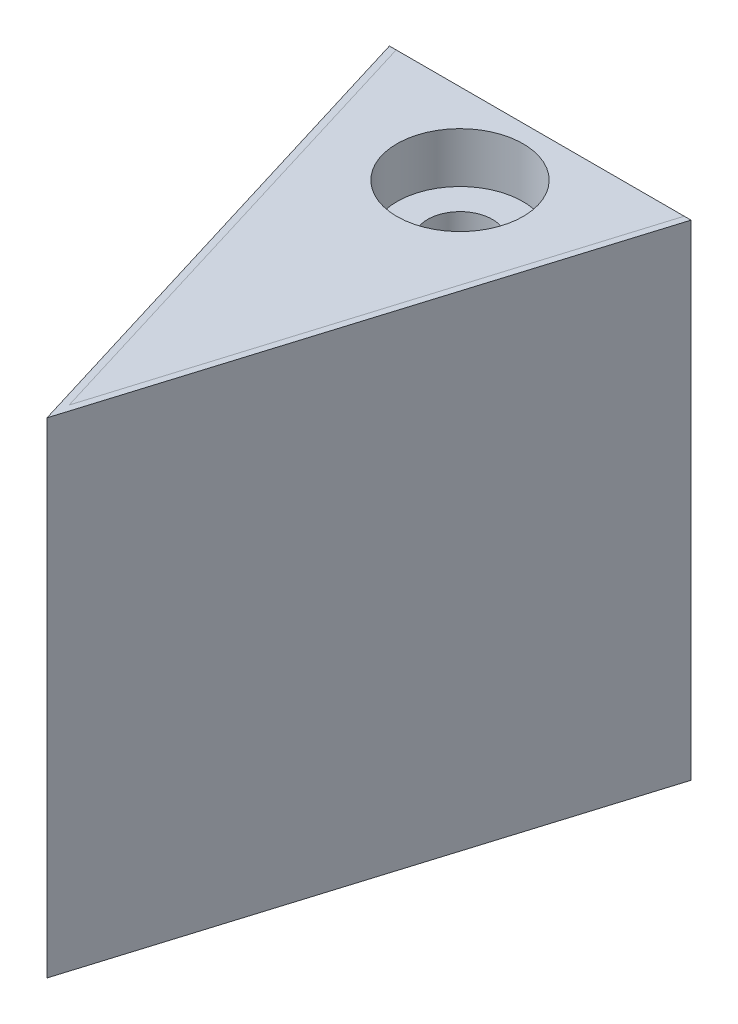
from build123d import *

# Parameters (mm, degrees)
BOSS_EXTRUDE1_DEPTH      = 12.5
BOSS_EXTRUDE1_DEPTH_BACK = 2.5
CUT_EXTRUDE1_DEPTH       = 5
SKETCH5_R                = 1
CUT_EXTRUDE2_DEPTH       = 22.965235397
CUT_EXTRUDE2_DEPTH_BACK  = 22.965235397
SKETCH6_R                = 1.95
CUT_EXTRUDE3_DEPTH       = 1.55
SPLIT2_SURFACE_1_BACK    = 24.335
SPLIT2_SURFACE_1_DEPTH   = 48.67
SPLIT2_SURFACE_2_BACK    = 24.335
SPLIT2_SURFACE_2_DEPTH   = 48.67


with BuildPart() as part:
    # Sketch1 → Boss-Extrude1 (new, two sides)
    with BuildSketch(Plane(origin=(0, 0, 0), x_dir=(1, 0, 0), z_dir=(0, 1, 0))) as boss_extrude1_sk:
        Polygon((4.642363604, -4.565370009), (-4.68242218, -4.565370009), (-1.013654003, -16.565370009), (-0.020029288, -19.815370009), (0.973595427, -16.565370009), align=None)
    extrude(amount=BOSS_EXTRUDE1_DEPTH)
    extrude(boss_extrude1_sk.sketch, amount=-BOSS_EXTRUDE1_DEPTH_BACK)

    # Sketch2 → Cut-Extrude1 (cut)
    with BuildSketch(Plane(origin=(0, 0, 4.565370009), x_dir=(-1, 0, 0), z_dir=(0, 0, -1))):
        with BuildLine():
            Line((-2.878246061, 5.95), (2.918304637, 5.95))
            ThreePointArc((2.918304637, 5.95), (0.020029288, 8.05), (-2.878246061, 5.95))
        make_face()
        with BuildLine():
            Line((-2.878246061, 4.05), (2.918304637, 4.05))
            ThreePointArc((2.918304637, 4.05), (0.020029288, 1.95), (-2.878246061, 4.05))
        make_face()
    extrude(amount=-CUT_EXTRUDE1_DEPTH, mode=Mode.SUBTRACT)

    # Sketch5 → Cut-Extrude2 (cut, two sides)
    with BuildSketch(Plane(origin=(0, 5.74, 0), x_dir=(1, 0, 0), z_dir=(0, 1, 0))) as cut_extrude2_sk:
        with Locations(Location((0, -7.065370009, 0), (0, 0, 270))):
            Circle(SKETCH5_R)
    extrude(amount=CUT_EXTRUDE2_DEPTH, mode=Mode.SUBTRACT)
    extrude(cut_extrude2_sk.sketch, amount=-CUT_EXTRUDE2_DEPTH_BACK, mode=Mode.SUBTRACT)

    # Sketch6 → Cut-Extrude3 (cut)
    with BuildSketch(Plane(origin=(0, 12.5, 0), x_dir=(1, 0, 0), z_dir=(0, 1, 0))):
        with Locations(Location((0, -7.065370009, 0), (0, 0, 270))):
            Circle(SKETCH6_R)
    extrude(amount=-CUT_EXTRUDE3_DEPTH, mode=Mode.SUBTRACT)


with BuildPart() as body_2:
    # Split2: the piece behind the surface
    add(part.part)
    # Split2 surface: a surface, the sketch's curves swept straight by 48.67 mm
    with BuildLine(Plane(origin=(0, 12.5, 0), x_dir=(1, 0, 0), z_dir=(0, 1, 0)).offset(-SPLIT2_SURFACE_1_BACK), mode=Mode.PRIVATE) as split2_surface_1_path:
        Line((-4.68242218, -4.565370009), (-0.020029288, -19.815370009))
        Line((-0.020029288, -19.815370009), (4.642363604, -4.565370009))
        Line((4.642363604, -4.565370009), (4.433225253, -4.565370009))
        Line((4.433225253, -4.565370009), (-0.020029288, -19.131309285))
        Line((-0.020029288, -19.131309285), (-4.473283829, -4.565370009))
        Line((-4.473283829, -4.565370009), (-4.68242218, -4.565370009))
    split2_surface_1 = Shell.extrude(split2_surface_1_path.wire(), (0 * SPLIT2_SURFACE_1_DEPTH, 1 * SPLIT2_SURFACE_1_DEPTH, 0 * SPLIT2_SURFACE_1_DEPTH))
    split(bisect_by=split2_surface_1, keep=Keep.BOTTOM)


with BuildPart() as part_1:
    add(part.part)

    # Split2: split by a surface, the side it looks to stays
    # Split2 surface: a surface, the sketch's curves swept straight by 48.67 mm
    with BuildLine(Plane(origin=(0, 12.5, 0), x_dir=(1, 0, 0), z_dir=(0, 1, 0)).offset(-SPLIT2_SURFACE_2_BACK), mode=Mode.PRIVATE) as split2_surface_2_path:
        Line((-4.68242218, -4.565370009), (-0.020029288, -19.815370009))
        Line((-0.020029288, -19.815370009), (4.642363604, -4.565370009))
        Line((4.642363604, -4.565370009), (4.433225253, -4.565370009))
        Line((4.433225253, -4.565370009), (-0.020029288, -19.131309285))
        Line((-0.020029288, -19.131309285), (-4.473283829, -4.565370009))
        Line((-4.473283829, -4.565370009), (-4.68242218, -4.565370009))
    split2_surface_2 = Shell.extrude(split2_surface_2_path.wire(), (0 * SPLIT2_SURFACE_2_DEPTH, 1 * SPLIT2_SURFACE_2_DEPTH, 0 * SPLIT2_SURFACE_2_DEPTH))
    split(bisect_by=split2_surface_2, keep=Keep.TOP)


solid = Compound([body_2.part, part_1.part])
